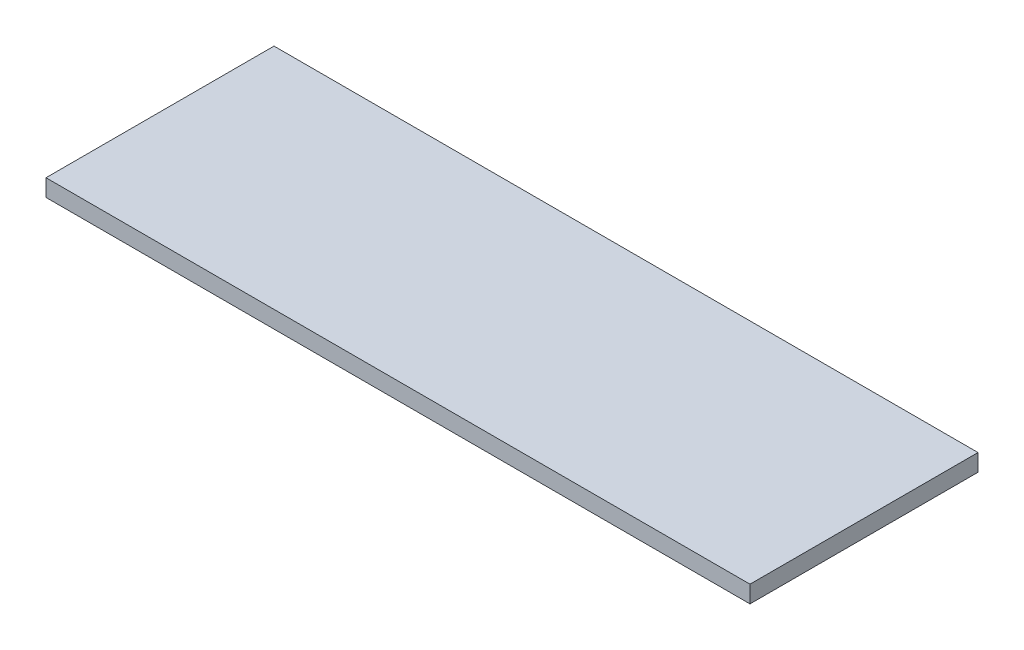
from build123d import *

# Parameters (mm, degrees)
SKETCH1_W           = 247
SKETCH1_H           = 80
BOSS_EXTRUDE1_DEPTH = 6


with BuildPart() as part:
    # Sketch1 → Boss-Extrude1 (new body)
    with BuildSketch(Plane(origin=(0, 0, 0), x_dir=(1, 0, 0), z_dir=(0, 1, 0))):
        with Locations((123.5, 40)):
            Rectangle(SKETCH1_W, SKETCH1_H)
    extrude(amount=BOSS_EXTRUDE1_DEPTH)


solid = part.part
